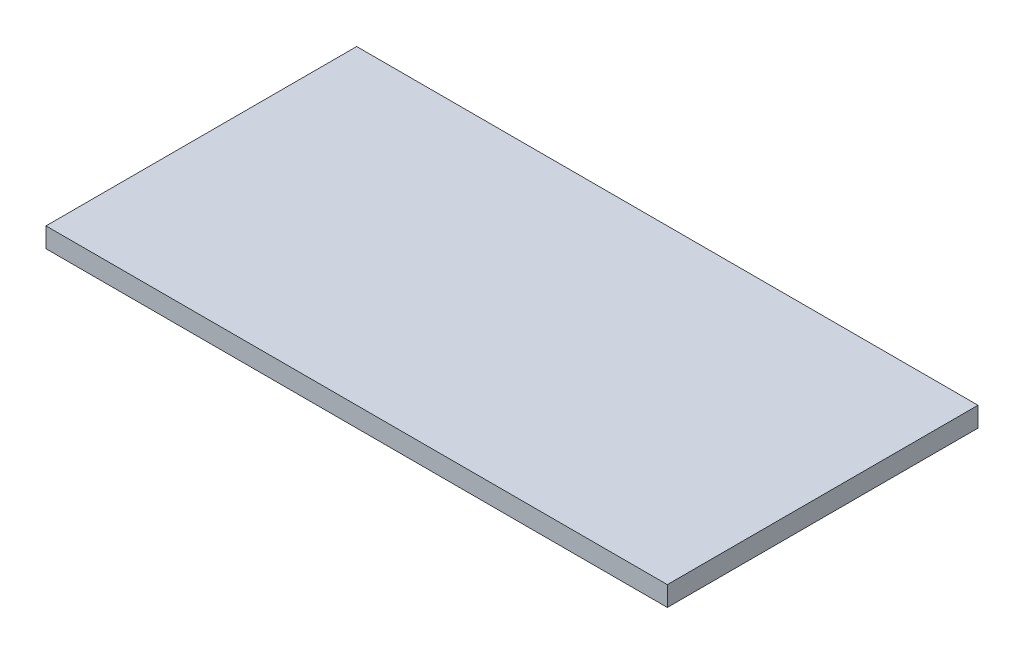
from build123d import *

# Parameters (mm, degrees)
SKETCH_1_W      = 564
SKETCH_1_H      = 282
EXTRUDE_1_DEPTH = 18


with BuildPart() as part:
    # Эскиз1 → Бобышка-Вытянуть1 (new body)
    with BuildSketch(Plane(origin=(0, 0, 0), x_dir=(1, 0, 0), z_dir=(0, 1, 0))):
        Rectangle(SKETCH_1_W, SKETCH_1_H)
    extrude(amount=EXTRUDE_1_DEPTH)


solid = part.part
